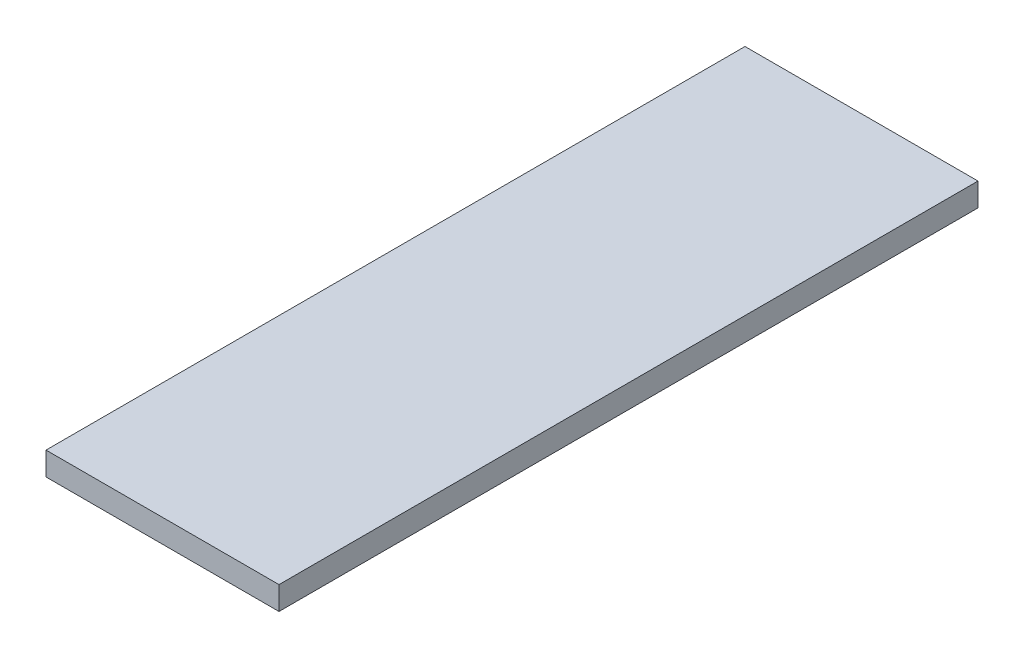
from build123d import *

# Parameters (mm, degrees)
ESQUISSE1_W        = 12
ESQUISSE1_H        = 36
BOSS_EXTRU_1_DEPTH = 1.2


with BuildPart() as part:
    # Esquisse1 → Boss.-Extru.1 (new body)
    with BuildSketch(Plane(origin=(0, 0, 0), x_dir=(1, 0, 0), z_dir=(0, 1, 0))):
        Rectangle(ESQUISSE1_W, ESQUISSE1_H)
    extrude(amount=BOSS_EXTRU_1_DEPTH)


solid = part.part
